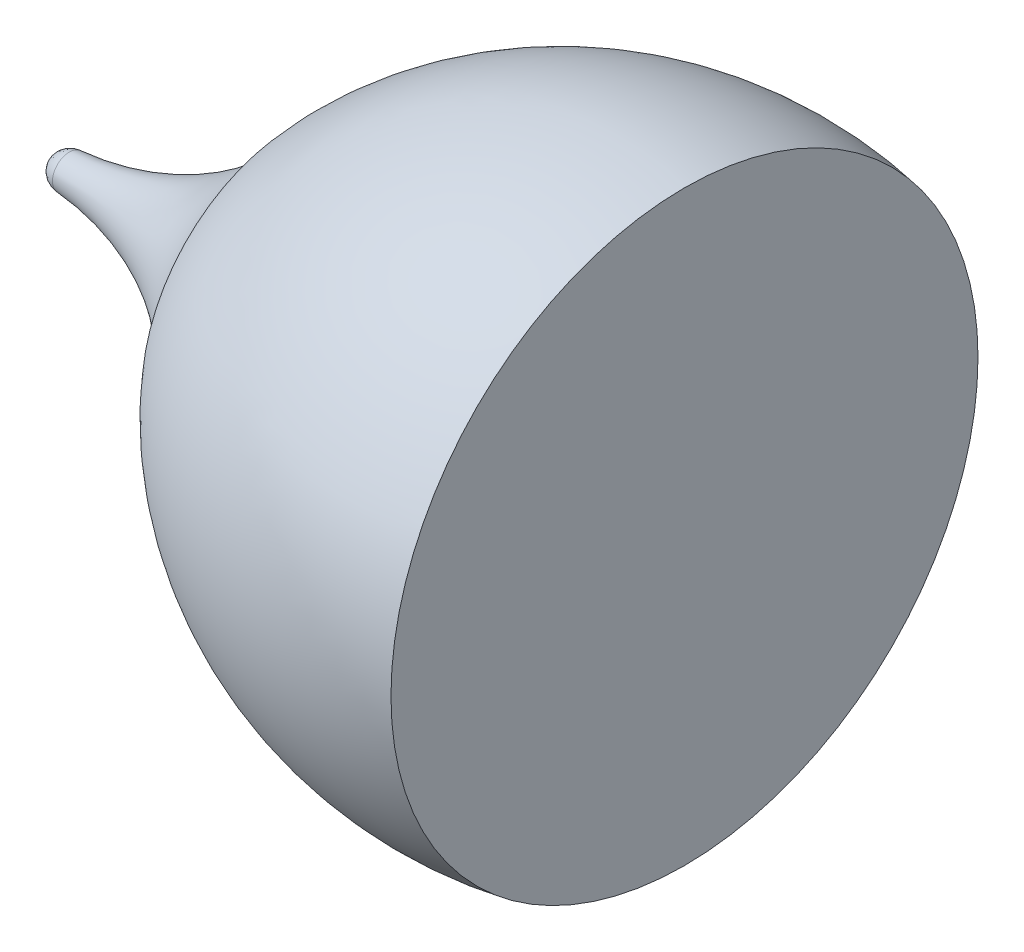
from build123d import *


with BuildPart() as part:
    # Sketch1 → Revolve1 (revolve)
    with BuildSketch(Plane.XY):
        with BuildLine():
            Line((-39.099540024, 5.100416614), (-16.810331023, 5.100416614))
            Line((-16.810331023, 5.100416614), (-16.810331023, 15.446032824))
            ThreePointArc((-16.810331023, 15.446032824), (-24.309753618, 14.817935256), (-30.498882941, 10.536519133))
            ThreePointArc((-30.498882941, 10.536519133), (-33.91003162, 7.147633312), (-38.493758542, 5.695073525))
            ThreePointArc((-38.493758542, 5.695073525), (-38.906341141, 5.509488993), (-39.099540024, 5.100416614))
        make_face()
    revolve(axis=Axis((-39.099540024, 5.100416614, 0), (1, 0, 0)))


solid = part.part
